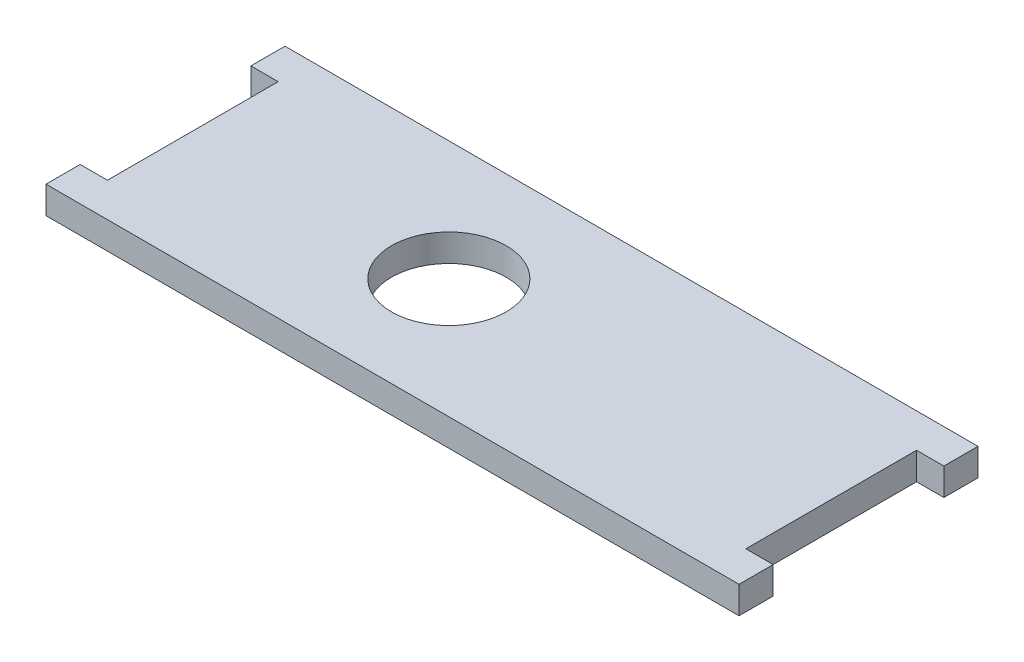
from build123d import *

# Parameters (mm, degrees)
SKETCH1_W           = 5.08
SKETCH1_H           = 6.35
SKETCH1_W_2         = 118.745
SKETCH1_H_2         = 44.45
SKETCH1_R           = 10.668
BOSS_EXTRUDE1_DEPTH = 5.08


with BuildPart() as part:
    # Sketch1 → Boss-Extrude1 (new body)
    with BuildSketch(Plane(origin=(0, 0, 0), x_dir=(1, 0, 0), z_dir=(0, 1, 0))):
        with Locations((-61.9125, -19.05)):
            Rectangle(SKETCH1_W, SKETCH1_H)
        with Locations((-61.9125, 19.05)):
            Rectangle(SKETCH1_W, SKETCH1_H)
        Rectangle(SKETCH1_W_2, SKETCH1_H_2)
        with Locations((-11.7475, 0)):
            Circle(SKETCH1_R, mode=Mode.SUBTRACT)
        with Locations((61.9125, 19.05)):
            Rectangle(SKETCH1_W, SKETCH1_H)
        with Locations((61.9125, -19.05)):
            Rectangle(SKETCH1_W, SKETCH1_H)
    extrude(amount=BOSS_EXTRUDE1_DEPTH)


solid = part.part
